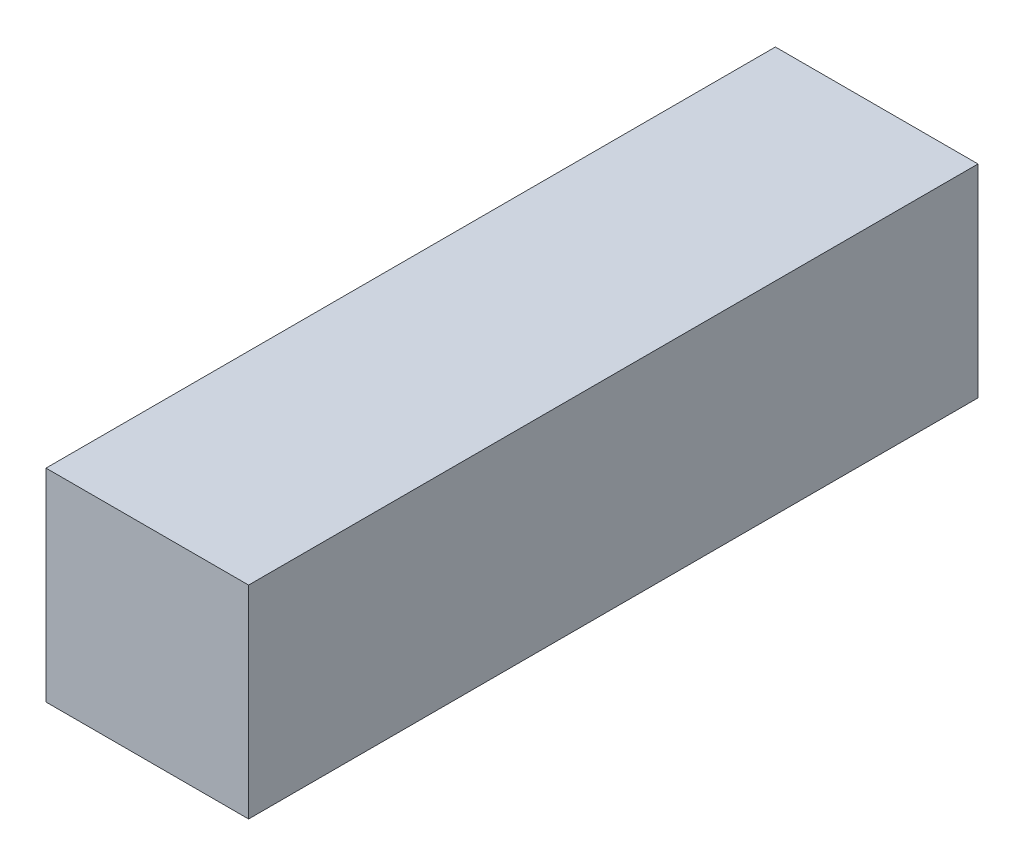
from build123d import *

# Parameters (mm, degrees)
ESBO_O2_W                = 50
ESBO_O2_H                = 50
RESSALTO_EXTRUS_O1_DEPTH = 180


with BuildPart() as part:
    # Esboço2 → Ressalto-extrusão1 (new body)
    with BuildSketch(Plane.XY):
        with Locations((-142.893120649, -6.329113924)):
            Rectangle(ESBO_O2_W, ESBO_O2_H)
    extrude(amount=RESSALTO_EXTRUS_O1_DEPTH)


solid = part.part
